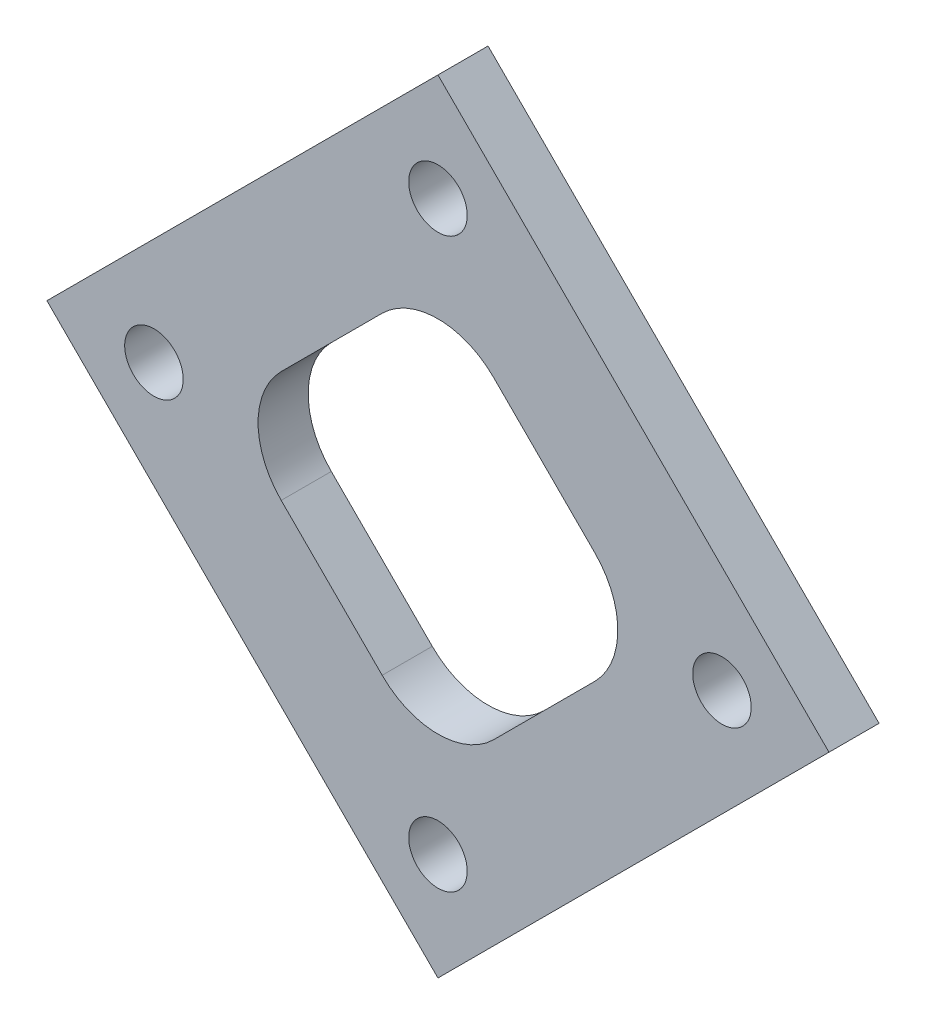
from build123d import *

# Parameters (mm, degrees)
SKETCH2_R           = 1.8542
BOSS_EXTRUDE1_DEPTH = 3.175
FILLET1_R           = 5


with BuildPart() as part:
    # Sketch2 → Boss-Extrude1 (new body)
    with BuildSketch(Plane.XY):
        Polygon((0, 24.784092681), (24.784092681, 0), (0, -24.784092681), (-24.784092681, 0), align=None)
        with Locations((0, 18)):
            Circle(SKETCH2_R, mode=Mode.SUBTRACT)
        with Locations((-18, 0)):
            Circle(SKETCH2_R, mode=Mode.SUBTRACT)
        with Locations((0, -18)):
            Circle(SKETCH2_R, mode=Mode.SUBTRACT)
        with Locations((18, 0)):
            Circle(SKETCH2_R, mode=Mode.SUBTRACT)
        Polygon((0, 13.470384182), (13.470384182, 0), (0, -13.470384182), (-13.470384182, 0), align=None, mode=Mode.SUBTRACT)
    extrude(amount=BOSS_EXTRUDE1_DEPTH)

    # Fillet1
    fillet1_edges = [part.edges().sort_by_distance(p)[0] for p in [
        (-13.470384182, 0, 1.5875),
        (0, -13.470384182, 1.5875),
        (13.470384182, 0, 1.5875),
        (0, 13.470384182, 1.5875),
    ]]
    fillet(fillet1_edges, radius=FILLET1_R)


solid = part.part
